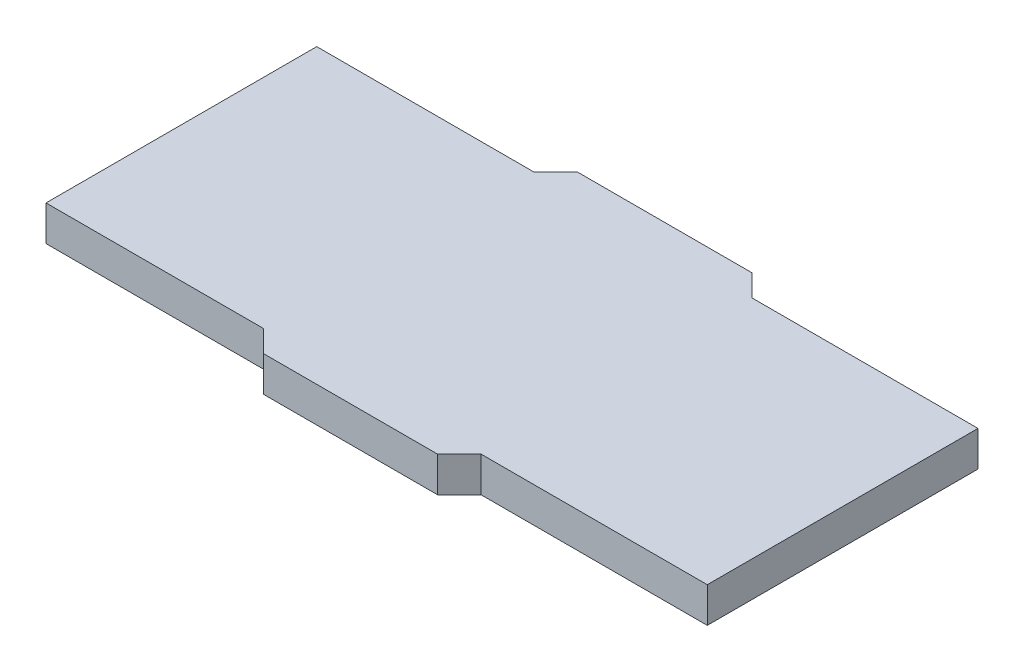
from build123d import *

# Parameters (mm, degrees)
BOSS_EXTRUDE1_DEPTH = 1.62


with BuildPart() as part:
    # Sketch1 → Boss-Extrude1 (new body)
    with BuildSketch(Plane(origin=(0, 0, 0), x_dir=(1, 0, 0), z_dir=(0, 1, 0))):
        Polygon((0, -6.223), (10, -6.223), (11, -7.223), (19, -7.223), (20, -6.223), (30.4, -6.223), (30.4, 6.223), (20, 6.223), (19, 7.223), (11, 7.223), (10, 6.223), (0, 6.223), align=None)
    extrude(amount=BOSS_EXTRUDE1_DEPTH)


solid = part.part
